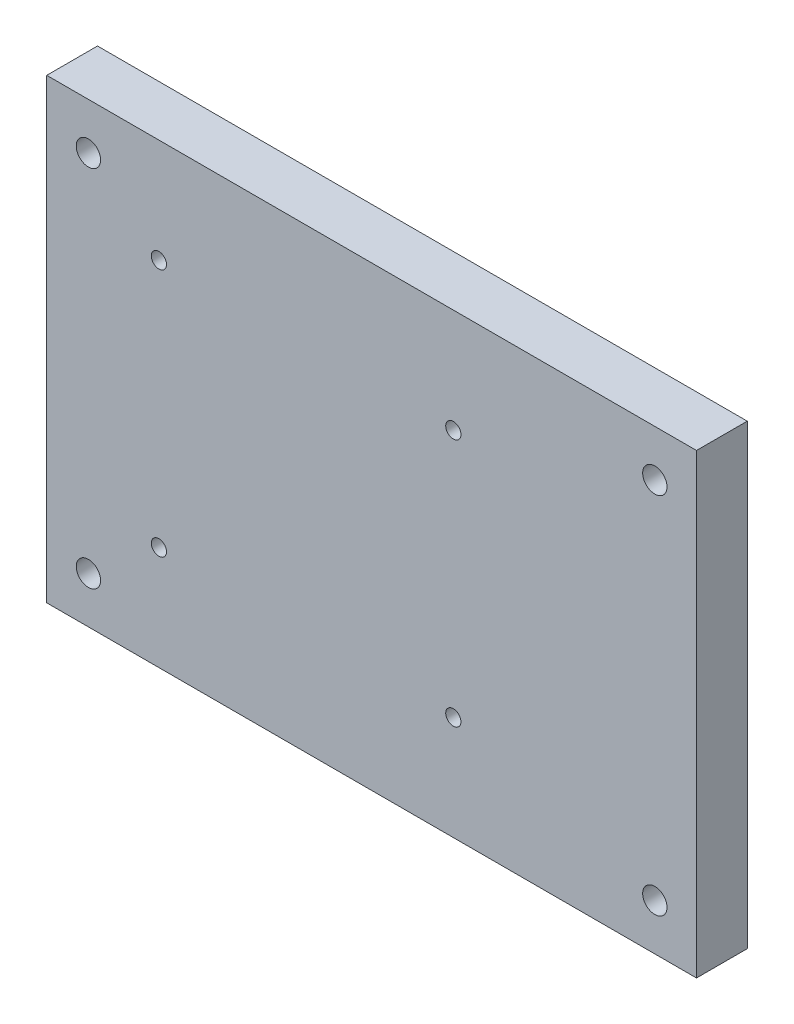
from build123d import *

# Parameters (mm, degrees)
SKETCH1_W           = 128
SKETCH1_H           = 90
SKETCH1_R           = 2.4
SKETCH1_R_2         = 1.5
BOSS_EXTRUDE3_DEPTH = 10


with BuildPart() as part:
    # Sketch1 → Boss-Extrude3 (new body)
    with BuildSketch(Plane.XY):
        with Locations((-55.79, 35.875)):
            Rectangle(SKETCH1_W, SKETCH1_H)
        with Locations((0, 71.73)):
            Circle(SKETCH1_R, mode=Mode.SUBTRACT)
        with Locations((-111.58, 0)):
            Circle(SKETCH1_R, mode=Mode.SUBTRACT)
        Circle(SKETCH1_R, mode=Mode.SUBTRACT)
        with Locations((-111.58, 71.73)):
            Circle(SKETCH1_R, mode=Mode.SUBTRACT)
        with Locations((-97.694375804, 60.375)):
            Circle(SKETCH1_R_2, mode=Mode.SUBTRACT)
        with Locations((-39.694375804, 60.375)):
            Circle(SKETCH1_R_2, mode=Mode.SUBTRACT)
        with Locations((-39.694375804, 11.375)):
            Circle(SKETCH1_R_2, mode=Mode.SUBTRACT)
        with Locations((-97.694375804, 11.375)):
            Circle(SKETCH1_R_2, mode=Mode.SUBTRACT)
    extrude(amount=BOSS_EXTRUDE3_DEPTH)


solid = part.part
